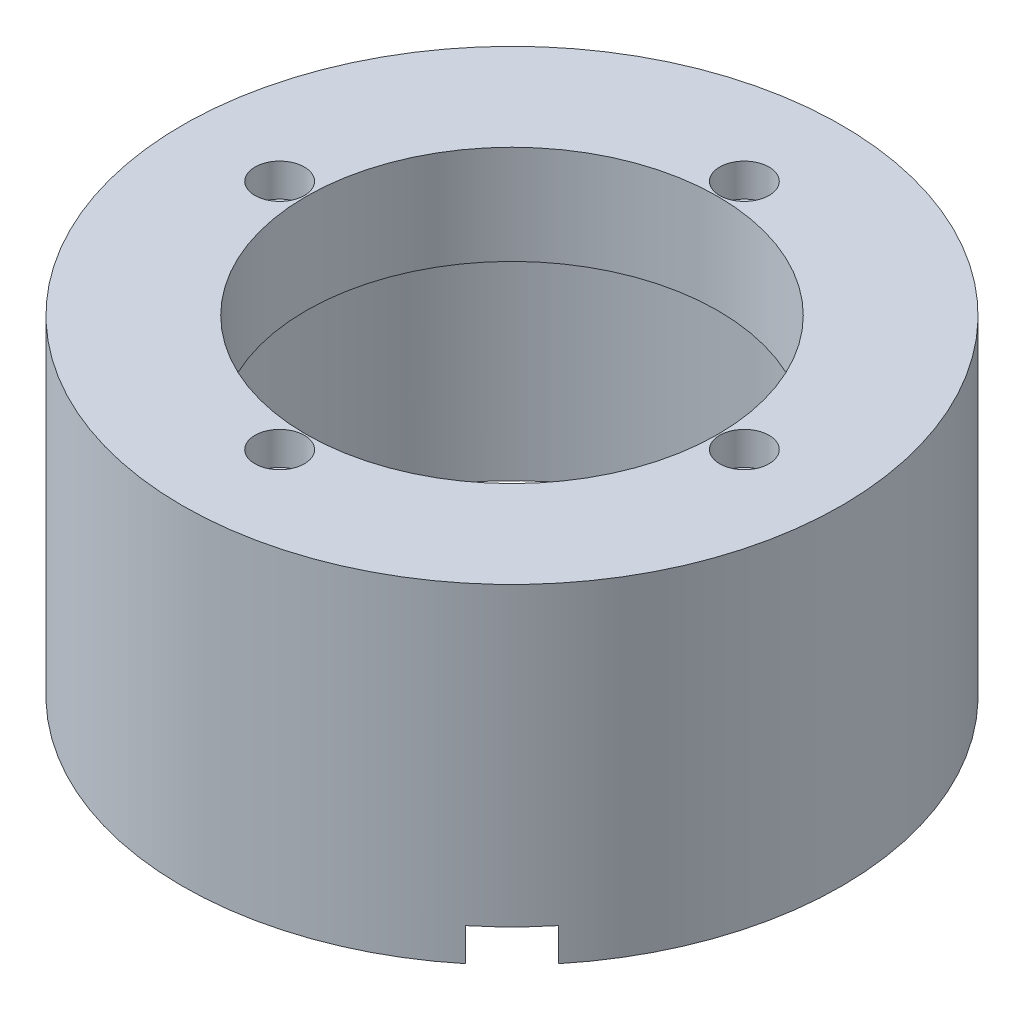
from build123d import *

# Parameters (mm, degrees)
CROQUIS1_R              = 50
CROQUIS1_R_2            = 31.25
SALIENTE_EXTRUIR1_DEPTH = 50
CROQUIS2_R              = 40
CORTAR_EXTRUIR1_DEPTH   = 35
CROQUIS3_R              = 1.5
CORTAR_EXTRUIR2_DEPTH   = 35
CROQUIS3_3_R            = 2
CORTAR_EXTRUIR3_DEPTH   = 87.602540378
CROQUIS4_R              = 3.75
CORTAR_EXTRUIR4_DEPTH   = 5
CORTAR_EXTRUIR5_DEPTH   = 5


with BuildPart() as part:
    # Croquis1 → Saliente-Extruir1 (new body)
    with BuildSketch(Plane(origin=(0, 0, 0), x_dir=(1, 0, 0), z_dir=(0, 1, 0))):
        Circle(CROQUIS1_R)
        Circle(CROQUIS1_R_2, mode=Mode.SUBTRACT)
    extrude(amount=SALIENTE_EXTRUIR1_DEPTH)

    # Croquis2 → Cortar-Extruir1 (cut)
    with BuildSketch(Plane.XZ):
        Circle(CROQUIS2_R)
    extrude(amount=-CORTAR_EXTRUIR1_DEPTH, mode=Mode.SUBTRACT)

    # Croquis3 → Cortar-Extruir2 (cut)
    with BuildSketch(Plane.XZ):
        with Locations((0, 45)):
            Circle(CROQUIS3_R)
        with Locations((45, 0)):
            Circle(CROQUIS3_R)
        with Locations((0, -45)):
            Circle(CROQUIS3_R)
        with Locations((-45, 0)):
            Circle(CROQUIS3_R)
    extrude(amount=-CORTAR_EXTRUIR2_DEPTH, mode=Mode.SUBTRACT)

    # Croquis3_3 → Cortar-Extruir3 (cut, through all)
    with BuildSketch(Plane.XZ):
        with Locations((0, 35.25)):
            Circle(CROQUIS3_3_R)
        with Locations((35.25, 0)):
            Circle(CROQUIS3_3_R)
        with Locations((0, -35.25)):
            Circle(CROQUIS3_3_R)
        with Locations((-35.25, 0)):
            Circle(CROQUIS3_3_R)
    extrude(amount=-CORTAR_EXTRUIR3_DEPTH, mode=Mode.SUBTRACT)

    # Croquis4 → Cortar-Extruir4 (cut)
    with BuildSketch(Plane(origin=(0, 50, 0), x_dir=(1, 0, 0), z_dir=(0, 1, 0))):
        with Locations((0, 35.25)):
            Circle(CROQUIS4_R)
        with Locations((35.25, 0)):
            Circle(CROQUIS4_R)
        with Locations((0, -35.25)):
            Circle(CROQUIS4_R)
        with Locations((-35.25, 0)):
            Circle(CROQUIS4_R)
    extrude(amount=-CORTAR_EXTRUIR4_DEPTH, mode=Mode.SUBTRACT)

    # Croquis8 → Cortar-Extruir5 (cut)
    with BuildSketch(Plane.XZ):
        with BuildLine():
            ThreePointArc((38.713652105, 31.642584293), (35.355339059, 35.355339059), (31.642584293, 38.713652105))
            Line((31.642584293, 38.713652105), (24.526896495, 31.597964307))
            ThreePointArc((24.526896495, 31.597964307), (28.284271247, 28.284271247), (31.597964307, 24.526896495))
            Line((31.597964307, 24.526896495), (38.713652105, 31.642584293))
        make_face()
    extrude(amount=-CORTAR_EXTRUIR5_DEPTH, mode=Mode.SUBTRACT)


solid = part.part
